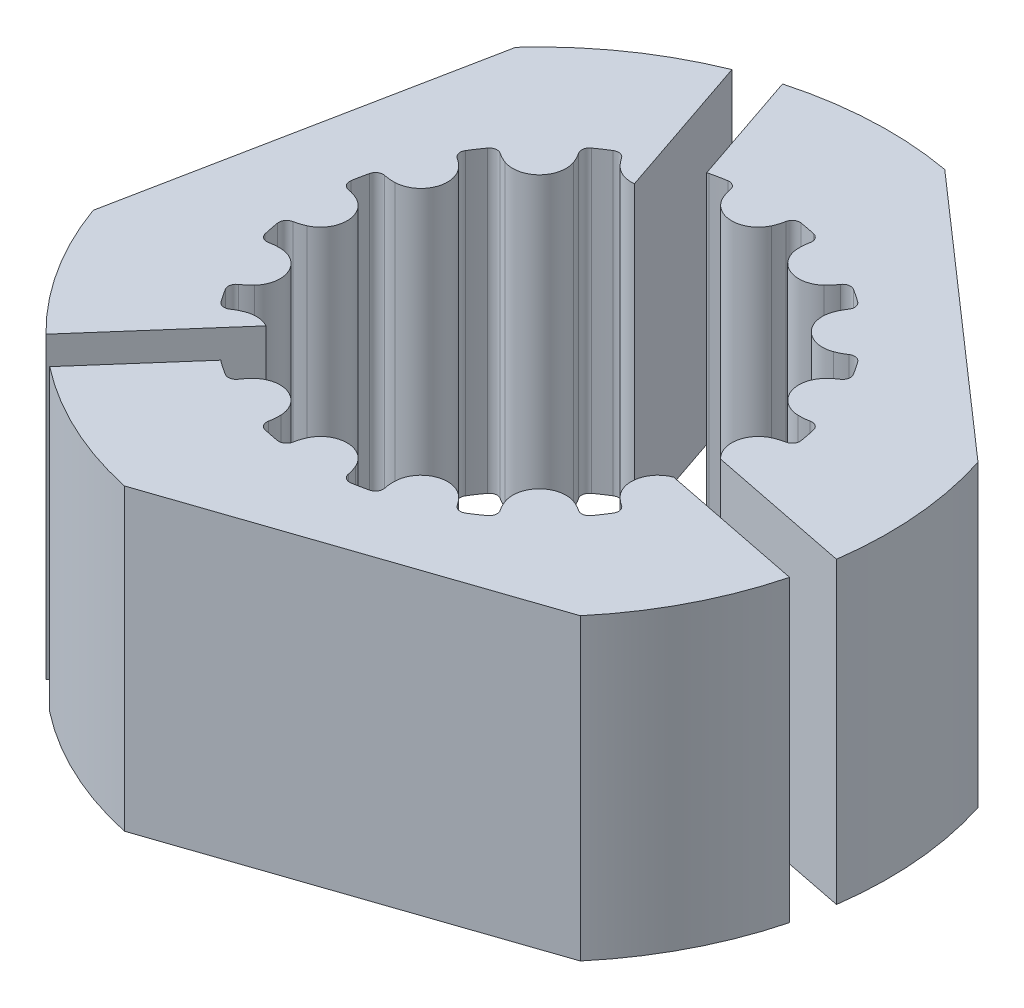
from build123d import *

# Parameters (mm, degrees)
SKETCH1_R             = 2.5
BOSS_EXTRUDE1_DEPTH   = 4.7625
SKETCH2_R             = 7.9375
SKETCH2_R_2           = 2.5
BOSS_EXTRUDE2_DEPTH   = 0.762
SKETCH4_R             = 1
CUT_EXTRUDE2_DEPTH    = 10.525
SKETCH5_R             = 1.25
CUT_EXTRUDE3_DEPTH    = 1.762
BOSS_EXTRUDE3_DEPTH   = 9.525
BOSS_EXTRUDE3_2_DEPTH = 9.525
BOSS_EXTRUDE3_3_DEPTH = 9.525


with BuildPart() as part:
    # Sketch1 → Boss-Extrude1 (new body, symmetric)
    with BuildSketch(Plane(origin=(0, 0, 0), x_dir=(1, 0, 0), z_dir=(0, 1, 0))):
        with BuildLine():
            ThreePointArc((-1.850768, -6.777037356), (-1.816941892, -6.962421006), (-1.663291889, -7.071521784))
            ThreePointArc((-1.663291889, -7.071521784), (-1.417233644, -7.124914669), (-1.169472895, -7.169748489))
            ThreePointArc((-1.169472895, -7.169748489), (-0.985767742, -7.127751824), (-0.883573242, -6.969424355))
            ThreePointArc((-0.883573242, -6.969424355), (-0.839120956, -6.792881518), (-0.773880597, -6.622919538))
            ThreePointArc((-0.773880597, -6.622919538), (0, -6.1245), (0.773880597, -6.622919538))
            ThreePointArc((0.773880597, -6.622919538), (0.839120956, -6.792881518), (0.883573242, -6.969424355))
            ThreePointArc((0.883573242, -6.969424355), (0.985767742, -7.127751824), (1.169472895, -7.169748489))
            ThreePointArc((1.169472895, -7.169748489), (1.417233644, -7.124914669), (1.663291889, -7.071521784))
            ThreePointArc((1.663291889, -7.071521784), (1.816941892, -6.962421006), (1.850768, -6.777037356))
            ThreePointArc((1.850768, -6.777037356), (1.824276538, -6.596921889), (1.819509137, -6.414931089))
            ThreePointArc((1.819509137, -6.414931089), (2.343744682, -5.658300197), (3.249454025, -5.822628523))
            ThreePointArc((3.249454025, -5.822628523), (3.374769892, -5.954686513), (3.483398468, -6.100779674))
            ThreePointArc((3.483398468, -6.100779674), (3.638403174, -6.20794704), (3.824196033, -6.176445981))
            ThreePointArc((3.824196033, -6.176445981), (4.035939958, -6.040210999), (4.242835561, -5.896719991))
            ThreePointArc((4.242835561, -5.896719991), (4.343038594, -5.737124705), (4.303346591, -5.552907854))
            ThreePointArc((4.303346591, -5.552907854), (4.209944466, -5.396640704), (4.135895098, -5.230327534))
            ThreePointArc((4.135895098, -5.230327534), (4.330675481, -4.330675481), (5.230327534, -4.135895098))
            ThreePointArc((5.230327534, -4.135895098), (5.396640704, -4.209944466), (5.552907854, -4.303346591))
            ThreePointArc((5.552907854, -4.303346591), (5.737124705, -4.343038594), (5.896719991, -4.242835561))
            ThreePointArc((5.896719991, -4.242835561), (6.040210999, -4.035939958), (6.176445981, -3.824196033))
            ThreePointArc((6.176445981, -3.824196033), (6.20794704, -3.638403174), (6.100779674, -3.483398468))
            ThreePointArc((6.100779674, -3.483398468), (5.954686513, -3.374769892), (5.822628523, -3.249454025))
            ThreePointArc((5.822628523, -3.249454025), (5.658300197, -2.343744682), (6.414931089, -1.819509137))
            ThreePointArc((6.414931089, -1.819509137), (6.596921889, -1.824276538), (6.777037356, -1.850768))
            ThreePointArc((6.777037356, -1.850768), (6.962421006, -1.816941892), (7.071521784, -1.663291889))
            ThreePointArc((7.071521784, -1.663291889), (7.124914669, -1.417233644), (7.169748489, -1.169472895))
            ThreePointArc((7.169748489, -1.169472895), (7.127751824, -0.985767742), (6.969424355, -0.883573242))
            ThreePointArc((6.969424355, -0.883573242), (6.792881518, -0.839120956), (6.622919538, -0.773880597))
            ThreePointArc((6.622919538, -0.773880597), (6.1245, 0), (6.622919538, 0.773880597))
            ThreePointArc((6.622919538, 0.773880597), (6.792881518, 0.839120956), (6.969424355, 0.883573242))
            ThreePointArc((6.969424355, 0.883573242), (7.127751824, 0.985767742), (7.169748489, 1.169472895))
            ThreePointArc((7.169748489, 1.169472895), (7.124914669, 1.417233644), (7.071521784, 1.663291889))
            ThreePointArc((7.071521784, 1.663291889), (6.962421006, 1.816941892), (6.777037356, 1.850768))
            ThreePointArc((6.777037356, 1.850768), (6.596921889, 1.824276538), (6.414931089, 1.819509137))
            ThreePointArc((6.414931089, 1.819509137), (5.658300197, 2.343744682), (5.822628523, 3.249454025))
            ThreePointArc((5.822628523, 3.249454025), (5.954686513, 3.374769892), (6.100779674, 3.483398468))
            ThreePointArc((6.100779674, 3.483398468), (6.20794704, 3.638403174), (6.176445981, 3.824196033))
            ThreePointArc((6.176445981, 3.824196033), (6.040210999, 4.035939958), (5.896719991, 4.242835561))
            ThreePointArc((5.896719991, 4.242835561), (5.737124705, 4.343038594), (5.552907854, 4.303346591))
            ThreePointArc((5.552907854, 4.303346591), (5.396640704, 4.209944466), (5.230327534, 4.135895098))
            ThreePointArc((5.230327534, 4.135895098), (4.330675481, 4.330675481), (4.135895098, 5.230327534))
            ThreePointArc((4.135895098, 5.230327534), (4.209944466, 5.396640704), (4.303346591, 5.552907854))
            ThreePointArc((4.303346591, 5.552907854), (4.343038594, 5.737124705), (4.242835561, 5.896719991))
            ThreePointArc((4.242835561, 5.896719991), (4.035939958, 6.040210999), (3.824196033, 6.176445981))
            ThreePointArc((3.824196033, 6.176445981), (3.638403174, 6.20794704), (3.483398468, 6.100779674))
            ThreePointArc((3.483398468, 6.100779674), (3.374769892, 5.954686513), (3.249454025, 5.822628523))
            ThreePointArc((3.249454025, 5.822628523), (2.343744682, 5.658300197), (1.819509137, 6.414931089))
            ThreePointArc((1.819509137, 6.414931089), (1.824276538, 6.596921889), (1.850768, 6.777037356))
            ThreePointArc((1.850768, 6.777037356), (1.816941892, 6.962421006), (1.663291889, 7.071521784))
            ThreePointArc((1.663291889, 7.071521784), (1.417233644, 7.124914669), (1.169472895, 7.169748489))
            ThreePointArc((1.169472895, 7.169748489), (0.985767742, 7.127751824), (0.883573242, 6.969424355))
            ThreePointArc((0.883573242, 6.969424355), (0.839120956, 6.792881518), (0.773880597, 6.622919538))
            ThreePointArc((0.773880597, 6.622919538), (0, 6.1245), (-0.773880597, 6.622919538))
            ThreePointArc((-0.773880597, 6.622919538), (-0.839120956, 6.792881518), (-0.883573242, 6.969424355))
            ThreePointArc((-0.883573242, 6.969424355), (-0.985767742, 7.127751824), (-1.169472895, 7.169748489))
            ThreePointArc((-1.169472895, 7.169748489), (-1.417233644, 7.124914669), (-1.663291889, 7.071521784))
            ThreePointArc((-1.663291889, 7.071521784), (-1.816941892, 6.962421006), (-1.850768, 6.777037356))
            ThreePointArc((-1.850768, 6.777037356), (-1.824276538, 6.596921889), (-1.819509137, 6.414931089))
            ThreePointArc((-1.819509137, 6.414931089), (-2.343744682, 5.658300197), (-3.249454025, 5.822628523))
            ThreePointArc((-3.249454025, 5.822628523), (-3.374769892, 5.954686513), (-3.483398468, 6.100779674))
            ThreePointArc((-3.483398468, 6.100779674), (-3.638403174, 6.20794704), (-3.824196033, 6.176445981))
            ThreePointArc((-3.824196033, 6.176445981), (-4.035939958, 6.040210999), (-4.242835561, 5.896719991))
            ThreePointArc((-4.242835561, 5.896719991), (-4.343038594, 5.737124705), (-4.303346591, 5.552907854))
            ThreePointArc((-4.303346591, 5.552907854), (-4.209944466, 5.396640704), (-4.135895098, 5.230327534))
            ThreePointArc((-4.135895098, 5.230327534), (-4.330675481, 4.330675481), (-5.230327534, 4.135895098))
            ThreePointArc((-5.230327534, 4.135895098), (-5.396640704, 4.209944466), (-5.552907854, 4.303346591))
            ThreePointArc((-5.552907854, 4.303346591), (-5.737124705, 4.343038594), (-5.896719991, 4.242835561))
            ThreePointArc((-5.896719991, 4.242835561), (-6.040210999, 4.035939958), (-6.176445981, 3.824196033))
            ThreePointArc((-6.176445981, 3.824196033), (-6.20794704, 3.638403174), (-6.100779674, 3.483398468))
            ThreePointArc((-6.100779674, 3.483398468), (-5.954686513, 3.374769892), (-5.822628523, 3.249454025))
            ThreePointArc((-5.822628523, 3.249454025), (-5.658300197, 2.343744682), (-6.414931089, 1.819509137))
            ThreePointArc((-6.414931089, 1.819509137), (-6.596921889, 1.824276538), (-6.777037356, 1.850768))
            ThreePointArc((-6.777037356, 1.850768), (-6.962421006, 1.816941892), (-7.071521784, 1.663291889))
            ThreePointArc((-7.071521784, 1.663291889), (-7.124914669, 1.417233644), (-7.169748489, 1.169472895))
            ThreePointArc((-7.169748489, 1.169472895), (-7.127751824, 0.985767742), (-6.969424355, 0.883573242))
            ThreePointArc((-6.969424355, 0.883573242), (-6.792881518, 0.839120956), (-6.622919538, 0.773880597))
            ThreePointArc((-6.622919538, 0.773880597), (-6.1245, 0), (-6.622919538, -0.773880597))
            ThreePointArc((-6.622919538, -0.773880597), (-6.792881518, -0.839120956), (-6.969424355, -0.883573242))
            ThreePointArc((-6.969424355, -0.883573242), (-7.127751824, -0.985767742), (-7.169748489, -1.169472895))
            ThreePointArc((-7.169748489, -1.169472895), (-7.124914669, -1.417233644), (-7.071521784, -1.663291889))
            ThreePointArc((-7.071521784, -1.663291889), (-6.962421006, -1.816941892), (-6.777037356, -1.850768))
            ThreePointArc((-6.777037356, -1.850768), (-6.596921889, -1.824276538), (-6.414931089, -1.819509137))
            ThreePointArc((-6.414931089, -1.819509137), (-5.658300197, -2.343744682), (-5.822628523, -3.249454025))
            ThreePointArc((-5.822628523, -3.249454025), (-5.954686513, -3.374769892), (-6.100779674, -3.483398468))
            ThreePointArc((-6.100779674, -3.483398468), (-6.20794704, -3.638403174), (-6.176445981, -3.824196033))
            ThreePointArc((-6.176445981, -3.824196033), (-6.040210999, -4.035939958), (-5.896719991, -4.242835561))
            ThreePointArc((-5.896719991, -4.242835561), (-5.737124705, -4.343038594), (-5.552907854, -4.303346591))
            ThreePointArc((-5.552907854, -4.303346591), (-5.396640704, -4.209944466), (-5.230327534, -4.135895098))
            ThreePointArc((-5.230327534, -4.135895098), (-4.330675481, -4.330675481), (-4.135895098, -5.230327534))
            ThreePointArc((-4.135895098, -5.230327534), (-4.209944466, -5.396640704), (-4.303346591, -5.552907854))
            ThreePointArc((-4.303346591, -5.552907854), (-4.343038594, -5.737124705), (-4.242835561, -5.896719991))
            ThreePointArc((-4.242835561, -5.896719991), (-4.035939958, -6.040210999), (-3.824196033, -6.176445981))
            ThreePointArc((-3.824196033, -6.176445981), (-3.638403174, -6.20794704), (-3.483398468, -6.100779674))
            ThreePointArc((-3.483398468, -6.100779674), (-3.374769892, -5.954686513), (-3.249454025, -5.822628523))
            ThreePointArc((-3.249454025, -5.822628523), (-2.343744682, -5.658300197), (-1.819509137, -6.414931089))
            ThreePointArc((-1.819509137, -6.414931089), (-1.824276538, -6.596921889), (-1.850768, -6.777037356))
        make_face()
        Circle(SKETCH1_R, mode=Mode.SUBTRACT)
    extrude(amount=BOSS_EXTRUDE1_DEPTH, both=True)

    # Sketch4 → Cut-Extrude2 (cut, through all)
    with BuildSketch(Plane.XZ.offset(4.7625)):
        with Locations((-4.359590571, 0.867176481)):
            Circle(SKETCH4_R)
        with Locations((4.359590571, -0.867176481)):
            Circle(SKETCH4_R)
    extrude(amount=-CUT_EXTRUDE2_DEPTH, mode=Mode.SUBTRACT)


with BuildPart() as body_2:
    # Sketch2 → Boss-Extrude2 (new body)
    with BuildSketch(Plane.XZ.offset(4.7625)):
        Circle(SKETCH2_R)
        Circle(SKETCH2_R_2, mode=Mode.SUBTRACT)
    extrude(amount=BOSS_EXTRUDE2_DEPTH)

    # Sketch5 → Cut-Extrude3 (cut, through all)
    with BuildSketch(Plane(origin=(0, -4.7625, 0), x_dir=(1, 0, 0), z_dir=(0, 1, 0))):
        with Locations((-4.359590571, -0.867176481)):
            Circle(SKETCH5_R)
        with Locations((4.359590571, 0.867176481)):
            Circle(SKETCH5_R)
    extrude(amount=-CUT_EXTRUDE3_DEPTH, mode=Mode.SUBTRACT)


with BuildPart() as body_3:
    # Sketch6 → Boss-Extrude3 (new body)
    with BuildSketch(Plane(origin=(0, 4.7625, 0), x_dir=(1, 0, 0), z_dir=(0, 1, 0))):
        with BuildLine():
            Line((-2.964858827, 10.709681059), (-1.722377946, 7.049450412))
            ThreePointArc((-1.722377946, 7.049450412), (-1.693533772, 7.062356962), (-1.663291889, 7.071521784))
            ThreePointArc((-1.663291889, 7.071521784), (-1.417233644, 7.124914669), (-1.169472895, 7.169748489))
            ThreePointArc((-1.169472895, 7.169748489), (-0.985767742, 7.127751824), (-0.883573242, 6.969424355))
            ThreePointArc((-0.883573242, 6.969424355), (-0.839120956, 6.792881518), (-0.773880597, 6.622919538))
            ThreePointArc((-0.773880597, 6.622919538), (0, 6.1245), (0.773880597, 6.622919538))
            ThreePointArc((0.773880597, 6.622919538), (0.839120956, 6.792881518), (0.883573242, 6.969424355))
            ThreePointArc((0.883573242, 6.969424355), (0.985767742, 7.127751824), (1.169472895, 7.169748489))
            ThreePointArc((1.169472895, 7.169748489), (1.417233644, 7.124914669), (1.663291889, 7.071521784))
            ThreePointArc((1.663291889, 7.071521784), (1.816941892, 6.962421006), (1.850768, 6.777037356))
            ThreePointArc((1.850768, 6.777037356), (1.824276538, 6.596921889), (1.819509137, 6.414931089))
            ThreePointArc((1.819509137, 6.414931089), (2.343744682, 5.658300197), (3.249454025, 5.822628523))
            ThreePointArc((3.249454025, 5.822628523), (3.374769892, 5.954686513), (3.483398468, 6.100779674))
            ThreePointArc((3.483398468, 6.100779674), (3.638403174, 6.20794704), (3.824196033, 6.176445981))
            ThreePointArc((3.824196033, 6.176445981), (4.035939958, 6.040210999), (4.242835561, 5.896719991))
            ThreePointArc((4.242835561, 5.896719991), (4.343038594, 5.737124705), (4.303346591, 5.552907854))
            ThreePointArc((4.303346591, 5.552907854), (4.209944466, 5.396640704), (4.135895098, 5.230327534))
            ThreePointArc((4.135895098, 5.230327534), (4.330675481, 4.330675481), (5.230327534, 4.135895098))
            ThreePointArc((5.230327534, 4.135895098), (5.396640704, 4.209944466), (5.552907854, 4.303346591))
            ThreePointArc((5.552907854, 4.303346591), (5.737124705, 4.343038594), (5.896719991, 4.242835561))
            ThreePointArc((5.896719991, 4.242835561), (6.040210999, 4.035939958), (6.176445981, 3.824196033))
            ThreePointArc((6.176445981, 3.824196033), (6.20794704, 3.638403174), (6.100779674, 3.483398468))
            ThreePointArc((6.100779674, 3.483398468), (5.954686513, 3.374769892), (5.822628523, 3.249454025))
            ThreePointArc((5.822628523, 3.249454025), (5.658300197, 2.343744682), (6.414931089, 1.819509137))
            ThreePointArc((6.414931089, 1.819509137), (6.596921889, 1.824276538), (6.777037356, 1.850768))
            ThreePointArc((6.777037356, 1.850768), (6.962421006, 1.816941892), (7.071521784, 1.663291889))
            ThreePointArc((7.071521784, 1.663291889), (7.124914669, 1.417233644), (7.169748489, 1.169472895))
            ThreePointArc((7.169748489, 1.169472895), (7.127751824, 0.985767742), (6.969424355, 0.883573242))
            ThreePointArc((6.969424355, 0.883573242), (6.792881518, 0.839120956), (6.622919538, 0.773880597))
            ThreePointArc((6.622919538, 0.773880597), (6.135197418, 0.134429076), (6.398806324, -0.625361329))
            Line((6.398806324, -0.625361329), (11.005049986, -1.54160016))
            ThreePointArc((11.005049986, -1.54160016), (11.072109538, 0.946597392), (10.583659089, 3.387302249))
            Line((10.583659089, 3.387302249), (1.976878688, 10.935246083))
            ThreePointArc((1.976878688, 10.935246083), (-0.506701178, 11.100941859), (-2.964858827, 10.709681059))
        make_face()
    extrude(amount=-BOSS_EXTRUDE3_DEPTH)


with BuildPart() as body_4:
    # Sketch6 → Boss-Extrude3 2 (new body)
    with BuildSketch(Plane(origin=(0, 4.7625, 0), x_dir=(1, 0, 0), z_dir=(0, 1, 0))):
        with BuildLine():
            Line((-2.571273012, 5.599237431), (-4.167460092, 10.301452938))
            ThreePointArc((-4.167460092, 10.301452938), (-6.355832158, 9.115429438), (-8.225319343, 7.472066512))
            Line((-8.225319343, 7.472066512), (-10.458640249, -3.755595878))
            ThreePointArc((-10.458640249, -3.755595878), (-9.360347067, -5.989287022), (-7.79242645, -7.922483592))
            Line((-7.79242645, -7.922483592), (-4.518281907, -4.189037279))
            ThreePointArc((-4.518281907, -4.189037279), (-4.868454045, -4.084073695), (-5.230327534, -4.135895098))
            ThreePointArc((-5.230327534, -4.135895098), (-5.396640704, -4.209944466), (-5.552907854, -4.303346591))
            ThreePointArc((-5.552907854, -4.303346591), (-5.737124705, -4.343038594), (-5.896719991, -4.242835561))
            ThreePointArc((-5.896719991, -4.242835561), (-6.040210999, -4.035939958), (-6.176445981, -3.824196033))
            ThreePointArc((-6.176445981, -3.824196033), (-6.20794704, -3.638403174), (-6.100779674, -3.483398468))
            ThreePointArc((-6.100779674, -3.483398468), (-5.954686513, -3.374769892), (-5.822628523, -3.249454025))
            ThreePointArc((-5.822628523, -3.249454025), (-5.658300197, -2.343744682), (-6.414931089, -1.819509137))
            ThreePointArc((-6.414931089, -1.819509137), (-6.596921889, -1.824276538), (-6.777037356, -1.850768))
            ThreePointArc((-6.777037356, -1.850768), (-6.962421006, -1.816941892), (-7.071521784, -1.663291889))
            ThreePointArc((-7.071521784, -1.663291889), (-7.124914669, -1.417233644), (-7.169748489, -1.169472895))
            ThreePointArc((-7.169748489, -1.169472895), (-7.127751824, -0.985767742), (-6.969424355, -0.883573242))
            ThreePointArc((-6.969424355, -0.883573242), (-6.792881518, -0.839120956), (-6.622919538, -0.773880597))
            ThreePointArc((-6.622919538, -0.773880597), (-6.1245, 0), (-6.622919538, 0.773880597))
            ThreePointArc((-6.622919538, 0.773880597), (-6.792881518, 0.839120956), (-6.969424355, 0.883573242))
            ThreePointArc((-6.969424355, 0.883573242), (-7.127751824, 0.985767742), (-7.169748489, 1.169472895))
            ThreePointArc((-7.169748489, 1.169472895), (-7.124914669, 1.417233644), (-7.071521784, 1.663291889))
            ThreePointArc((-7.071521784, 1.663291889), (-6.962421006, 1.816941892), (-6.777037356, 1.850768))
            ThreePointArc((-6.777037356, 1.850768), (-6.596921889, 1.824276538), (-6.414931089, 1.819509137))
            ThreePointArc((-6.414931089, 1.819509137), (-5.658300197, 2.343744682), (-5.822628523, 3.249454025))
            ThreePointArc((-5.822628523, 3.249454025), (-5.954686513, 3.374769892), (-6.100779674, 3.483398468))
            ThreePointArc((-6.100779674, 3.483398468), (-6.20794704, 3.638403174), (-6.176445981, 3.824196033))
            ThreePointArc((-6.176445981, 3.824196033), (-6.040210999, 4.035939958), (-5.896719991, 4.242835561))
            ThreePointArc((-5.896719991, 4.242835561), (-5.737124705, 4.343038594), (-5.552907854, 4.303346591))
            ThreePointArc((-5.552907854, 4.303346591), (-5.396640704, 4.209944466), (-5.230327534, 4.135895098))
            ThreePointArc((-5.230327534, 4.135895098), (-4.330675481, 4.330675481), (-4.135895098, 5.230327534))
            ThreePointArc((-4.135895098, 5.230327534), (-4.209944466, 5.396640704), (-4.303346591, 5.552907854))
            ThreePointArc((-4.303346591, 5.552907854), (-4.343038594, 5.737124705), (-4.242835561, 5.896719991))
            ThreePointArc((-4.242835561, 5.896719991), (-4.035939958, 6.040210999), (-3.824196033, 6.176445981))
            ThreePointArc((-3.824196033, 6.176445981), (-3.638403174, 6.20794704), (-3.483398468, 6.100779674))
            ThreePointArc((-3.483398468, 6.100779674), (-3.374769892, 5.954686513), (-3.249454025, 5.822628523))
            ThreePointArc((-3.249454025, 5.822628523), (-2.934957708, 5.6362688), (-2.571273012, 5.599237431))
        make_face()
    extrude(amount=-BOSS_EXTRUDE3_2_DEPTH)


with BuildPart() as body_5:
    # Sketch6 → Boss-Extrude3 3 (new body)
    with BuildSketch(Plane(origin=(0, 4.7625, 0), x_dir=(1, 0, 0), z_dir=(0, 1, 0))):
        with BuildLine():
            ThreePointArc((8.481761561, -7.179650206), (9.867048245, -5.111654837), (10.757285277, -2.787197467))
            Line((10.757285277, -2.787197467), (6.151041615, -1.870958635))
            ThreePointArc((6.151041615, -1.870958635), (5.616739543, -2.472034678), (5.822628523, -3.249454025))
            ThreePointArc((5.822628523, -3.249454025), (5.954686513, -3.374769892), (6.100779674, -3.483398468))
            ThreePointArc((6.100779674, -3.483398468), (6.20794704, -3.638403174), (6.176445981, -3.824196033))
            ThreePointArc((6.176445981, -3.824196033), (6.040210999, -4.035939958), (5.896719991, -4.242835561))
            ThreePointArc((5.896719991, -4.242835561), (5.737124705, -4.343038594), (5.552907854, -4.303346591))
            ThreePointArc((5.552907854, -4.303346591), (5.396640704, -4.209944466), (5.230327534, -4.135895098))
            ThreePointArc((5.230327534, -4.135895098), (4.330675481, -4.330675481), (4.135895098, -5.230327534))
            ThreePointArc((4.135895098, -5.230327534), (4.209944466, -5.396640704), (4.303346591, -5.552907854))
            ThreePointArc((4.303346591, -5.552907854), (4.343038594, -5.737124705), (4.242835561, -5.896719991))
            ThreePointArc((4.242835561, -5.896719991), (4.035939958, -6.040210999), (3.824196033, -6.176445981))
            ThreePointArc((3.824196033, -6.176445981), (3.638403174, -6.20794704), (3.483398468, -6.100779674))
            ThreePointArc((3.483398468, -6.100779674), (3.374769892, -5.954686513), (3.249454025, -5.822628523))
            ThreePointArc((3.249454025, -5.822628523), (2.343744682, -5.658300197), (1.819509137, -6.414931089))
            ThreePointArc((1.819509137, -6.414931089), (1.824276538, -6.596921889), (1.850768, -6.777037356))
            ThreePointArc((1.850768, -6.777037356), (1.816941892, -6.962421006), (1.663291889, -7.071521784))
            ThreePointArc((1.663291889, -7.071521784), (1.417233644, -7.124914669), (1.169472895, -7.169748489))
            ThreePointArc((1.169472895, -7.169748489), (0.985767742, -7.127751824), (0.883573242, -6.969424355))
            ThreePointArc((0.883573242, -6.969424355), (0.839120956, -6.792881518), (0.773880597, -6.622919538))
            ThreePointArc((0.773880597, -6.622919538), (0, -6.1245), (-0.773880597, -6.622919538))
            ThreePointArc((-0.773880597, -6.622919538), (-0.839120956, -6.792881518), (-0.883573242, -6.969424355))
            ThreePointArc((-0.883573242, -6.969424355), (-0.985767742, -7.127751824), (-1.169472895, -7.169748489))
            ThreePointArc((-1.169472895, -7.169748489), (-1.417233644, -7.124914669), (-1.663291889, -7.071521784))
            ThreePointArc((-1.663291889, -7.071521784), (-1.816941892, -6.962421006), (-1.850768, -6.777037356))
            ThreePointArc((-1.850768, -6.777037356), (-1.824276538, -6.596921889), (-1.819509137, -6.414931089))
            ThreePointArc((-1.819509137, -6.414931089), (-2.343744682, -5.658300197), (-3.249454025, -5.822628523))
            ThreePointArc((-3.249454025, -5.822628523), (-3.374769892, -5.954686513), (-3.483398468, -6.100779674))
            ThreePointArc((-3.483398468, -6.100779674), (-3.638403174, -6.20794704), (-3.824196033, -6.176445981))
            ThreePointArc((-3.824196033, -6.176445981), (-4.035939958, -6.040210999), (-4.242835561, -5.896719991))
            ThreePointArc((-4.242835561, -5.896719991), (-4.267268192, -5.876679732), (-4.288977611, -5.853717447))
            Line((-4.288977611, -5.853717447), (-6.837589894, -8.759852778))
            ThreePointArc((-6.837589894, -8.759852778), (-4.716277381, -10.06202683), (-2.358339747, -10.859368761))
            Line((-2.358339747, -10.859368761), (8.481761561, -7.179650206))
        make_face()
    extrude(amount=-BOSS_EXTRUDE3_3_DEPTH)


solid = Compound([body_3.part, body_4.part, body_5.part])
